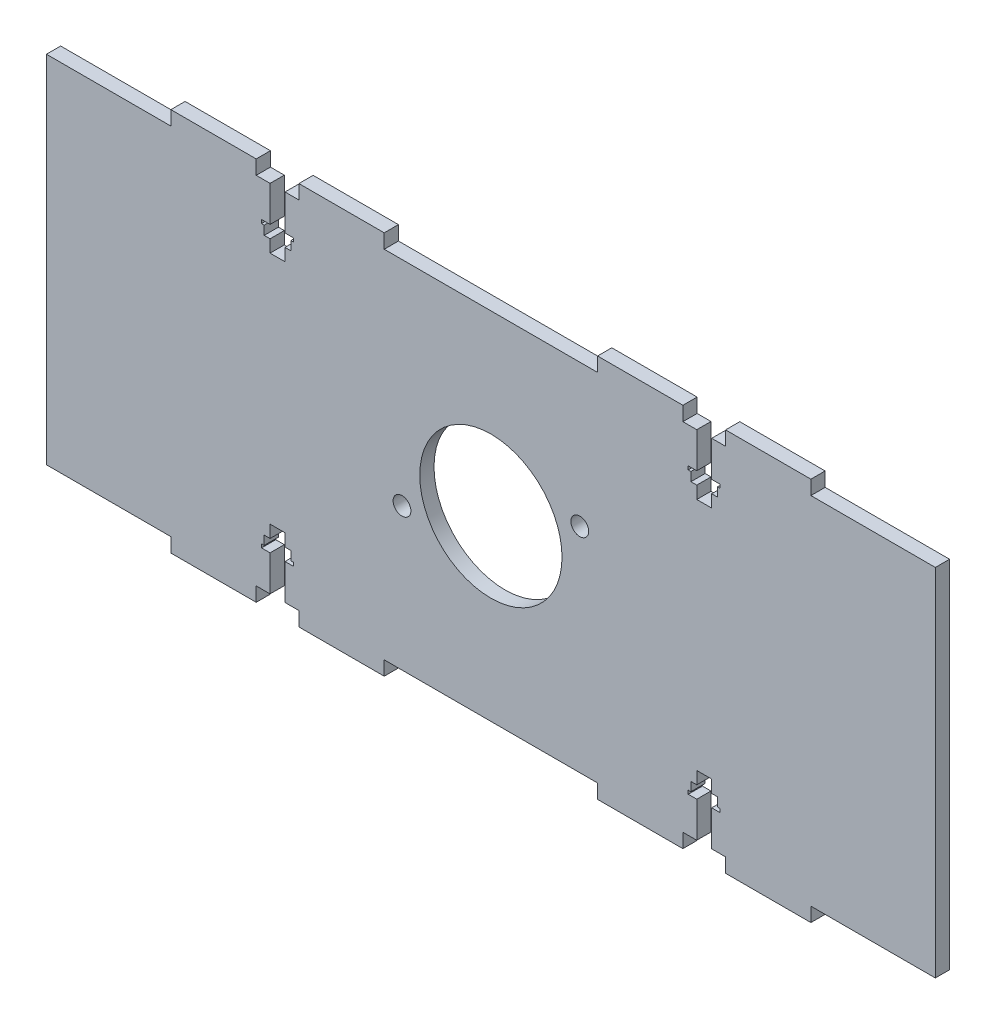
from build123d import *

# Parameters (mm, degrees)
SKETCH1_W           = 250
SKETCH1_H           = 100
BOSS_EXTRUDE1_DEPTH = 4
SKETCH2_W           = 24
SKETCH2_H           = 4
BOSS_EXTRUDE2_DEPTH = 4
CUT_EXTRUDE1_DEPTH  = 10
SKETCH4_R           = 20
SKETCH4_R_2         = 2.5
CUT_EXTRUDE2_DEPTH  = 10


with BuildPart() as part:
    # Sketch1 → Boss-Extrude1 (new body)
    with BuildSketch(Plane.XY):
        Rectangle(SKETCH1_W, SKETCH1_H)
    extrude(amount=BOSS_EXTRUDE1_DEPTH)

    # Sketch2 → Boss-Extrude2 (add)
    with BuildSketch(Plane.XZ.offset(50)):
        with Locations((-78, 2)):
            Rectangle(SKETCH2_W, SKETCH2_H)
        with Locations((-42, 2)):
            Rectangle(SKETCH2_W, SKETCH2_H)
        with Locations((42, 2)):
            Rectangle(SKETCH2_W, SKETCH2_H)
        with Locations((78, 2)):
            Rectangle(SKETCH2_W, SKETCH2_H)
    boss_extrude2 = extrude(amount=BOSS_EXTRUDE2_DEPTH)

    # Mirror1: Boss-Extrude2 across plane
    add(boss_extrude2.mirror(Plane.ZX))

    # Sketch3 → Cut-Extrude1 (cut)
    with BuildSketch(Plane(origin=(0, 0, 0), x_dir=(-1, 0, 0), z_dir=(0, 0, -1))):
        Polygon((-62.1, -50), (-57.9, -50), (-57.9, -40), (-55.5, -40), (-55.5, -39), (-56.25, -39), (-56.25, -36.5), (-57.9, -36.5), (-57.9, -33), (-62.1, -33), (-62.1, -36.5), (-63.75, -36.5), (-63.75, -39), (-64.5, -39), (-64.5, -40), (-62.1, -40), align=None)
        Polygon((57.9, -50), (57.9, -40), (55.5, -40), (55.5, -39), (56.25, -39), (56.25, -36.5), (57.9, -36.5), (57.9, -33), (62.1, -33), (62.1, -36.5), (63.75, -36.5), (63.75, -39), (64.5, -39), (64.5, -40), (62.1, -40), (62.1, -50), align=None)
        Polygon((62.1, 50), (57.9, 50), (57.9, 40), (55.5, 40), (55.5, 39), (56.25, 39), (56.25, 36.5), (57.9, 36.5), (57.9, 33), (62.1, 33), (62.1, 36.5), (63.75, 36.5), (63.75, 39), (64.5, 39), (64.5, 40), (62.1, 40), align=None)
        Polygon((-57.9, 50), (-57.9, 40), (-55.5, 40), (-55.5, 39), (-56.25, 39), (-56.25, 36.5), (-57.9, 36.5), (-57.9, 33), (-62.1, 33), (-62.1, 36.5), (-63.75, 36.5), (-63.75, 39), (-64.5, 39), (-64.5, 40), (-62.1, 40), (-62.1, 50), align=None)
    extrude(amount=-CUT_EXTRUDE1_DEPTH, mode=Mode.SUBTRACT)

    # Sketch4 → Cut-Extrude2 (cut)
    with BuildSketch(Plane(origin=(0, 0, 0), x_dir=(-1, 0, 0), z_dir=(0, 0, -1))):
        Circle(SKETCH4_R)
        with Locations((-25, 10)):
            Circle(SKETCH4_R_2)
        with Locations((25, -10)):
            Circle(SKETCH4_R_2)
    extrude(amount=-CUT_EXTRUDE2_DEPTH, mode=Mode.SUBTRACT)


solid = part.part
